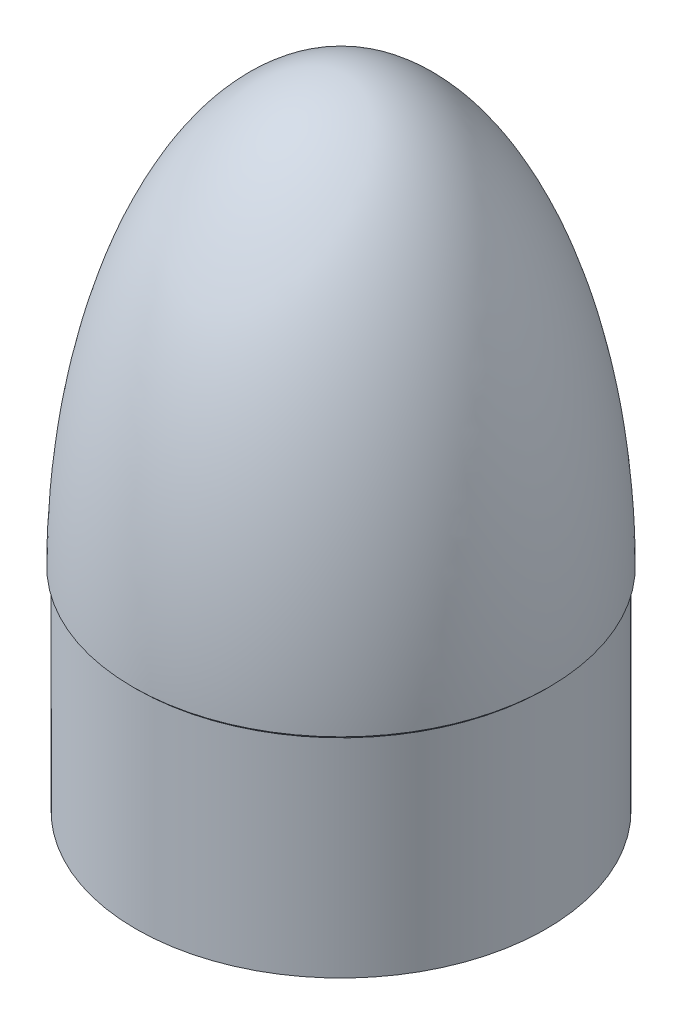
from build123d import *


with BuildPart() as part:
    # Sketch1 → Revolve1 (revolve)
    with BuildSketch(Plane.XY):
        with BuildLine():
            Line((0, 165.1), (0, 162.1))
            add(Edge.make_bspline(
                [(76.975, 0), (76.975, 162.1), (0, 162.1)],
                knots=[4.71238898, 4.71238898, 4.71238898, 6.283185307, 6.283185307, 6.283185307], degree=2, weights=[1, 0.707106781, 1]))
            Line((76.975, 0), (76.975, -81.661))
            Line((76.975, -81.661), (79.375, -81.661))
            Line((79.375, -81.661), (79.375, -1.143))
            Line((79.375, -1.143), (80.518, 0))
            add(Edge.make_bspline(
                [(80.518, 0), (80.518, 165.1), (0, 165.1)],
                knots=[1.570796327, 1.570796327, 1.570796327, 3.141592654, 3.141592654, 3.141592654], degree=2, weights=[1, 0.707106781, 1]))
        make_face()
    revolve(axis=Axis((0, 165.1, 0), (0, -1, 0)))


solid = part.part
